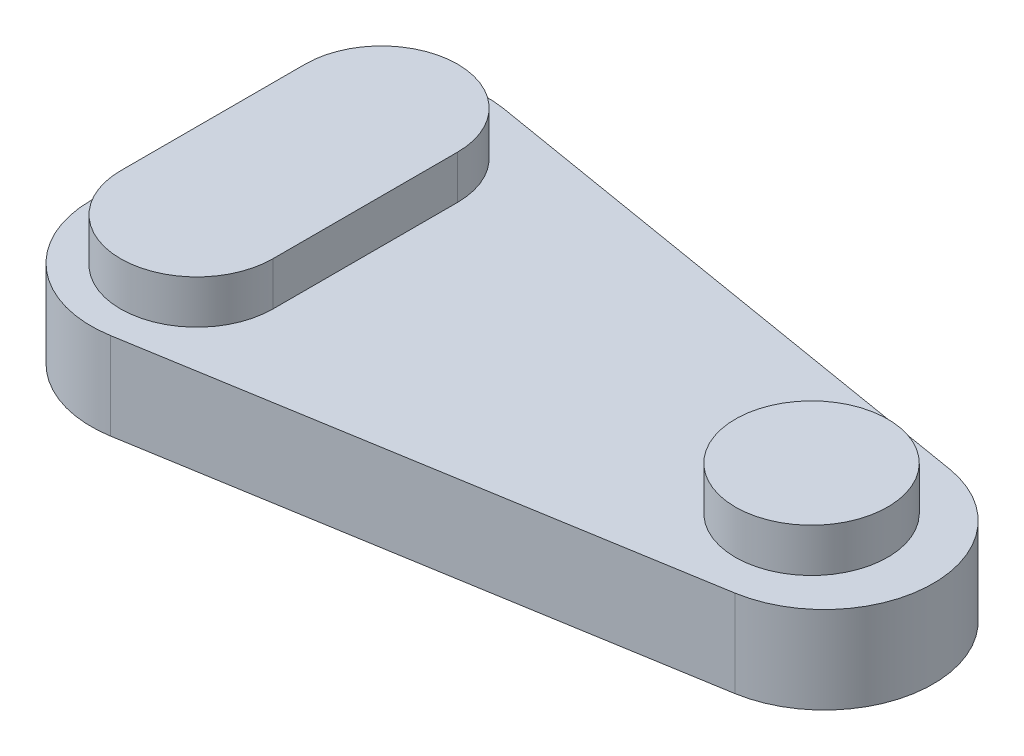
from build123d import *

# Parameters (mm, degrees)
BOSS_EXTRUDE1_DEPTH = 5.08
SKETCH5_R           = 4.445
BOSS_EXTRUDE2_DEPTH = 2.54


with BuildPart() as part:
    # Sketch1 → Boss-Extrude1 (new body)
    with BuildSketch(Plane(origin=(0, 0, 0), x_dir=(1, 0, 0), z_dir=(0, 1, 0))):
        with BuildLine():
            Line((0, 7.495923678), (0, 17.904076322))
            ThreePointArc((0, 17.904076322), (2.24551941, 22.749253211), (7.393933569, 24.167677738))
            Line((7.393933569, 24.167677738), (38.618391502, 18.963601416))
            ThreePointArc((38.618391502, 18.963601416), (43.924457933, 12.7), (38.618391502, 6.436398584))
            Line((38.618391502, 6.436398584), (7.393933569, 1.232322262))
            ThreePointArc((7.393933569, 1.232322262), (2.24551941, 2.650746789), (0, 7.495923678))
        make_face()
    extrude(amount=BOSS_EXTRUDE1_DEPTH)

    # Sketch5 → Boss-Extrude2 (add)
    with BuildSketch(Plane(origin=(0, 5.08, 0), x_dir=(1, 0, 0), z_dir=(0, 1, 0))):
        with BuildLine():
            Line((1.905, 18.086409435), (1.905, 7.313590565))
            ThreePointArc((1.905, 7.313590565), (6.35, 2.868590565), (10.795, 7.313590565))
            Line((10.795, 7.313590565), (10.795, 18.086409435))
            ThreePointArc((10.795, 18.086409435), (6.35, 22.531409435), (1.905, 18.086409435))
        make_face()
        with Locations((36.83, 12.7)):
            Circle(SKETCH5_R)
    extrude(amount=BOSS_EXTRUDE2_DEPTH)


solid = part.part
